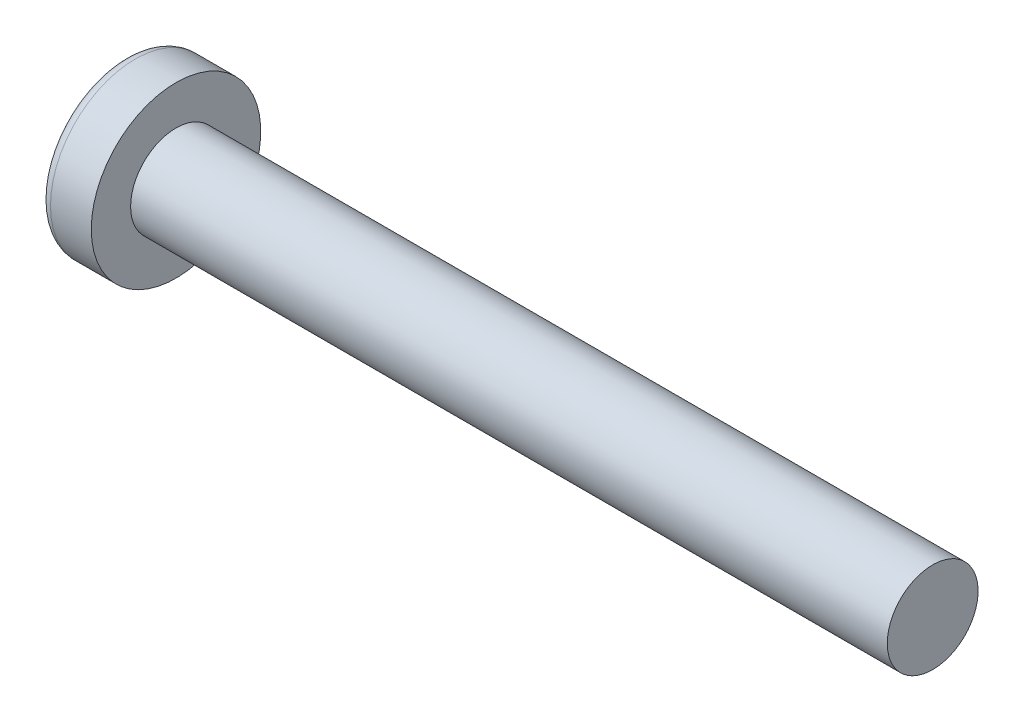
from build123d import *

# Parameters (mm, degrees)
SKETCH3_W         = 0.74
SKETCH3_H         = 2.9
SKETCH4_W         = 0.37
SKETCH4_H         = 0.37
CIRPATTERN1_COUNT = 2
CIRPATTERN1_ANGLE = 90


with BuildPart() as part:
    # BodySke → Base-Revolve (revolve)
    with BuildSketch(Plane.XY):
        with BuildLine():
            Line((2.4, 1.5), (2.4, 2.8))
            Line((2.4, 2.8), (1.053355856, 2.8))
            ThreePointArc((1.053355856, 2.8), (0.878072834, 2.754445324), (0.747150707, 2.629310345))
            ThreePointArc((0.747150707, 2.629310345), (0.190413403, 1.366702882), (0, 0))
            Line((0, 0), (27.4, 0))
            Line((27.4, 0), (27.4, 1.5))
            Line((27.4, 1.5), (2.4, 1.5))
        make_face()
    revolve(axis=Axis((-25.4, 0, 0), (1, 0, 0)))

    # Sketch3 → Cut-Loft1 section 0
    with BuildSketch(Plane(origin=(0, 0, 0), x_dir=(0, 0, -1), z_dir=(1, 0, 0))):
        Rectangle(SKETCH3_W, SKETCH3_H)
    # Sketch4 → Cut-Loft1 section 1
    with BuildSketch(Plane(origin=(1.76, 0, 0), x_dir=(0, 0, -1), z_dir=(1, 0, 0))):
        Rectangle(SKETCH4_W, SKETCH4_H)
    cut_loft1 = loft(mode=Mode.SUBTRACT)

    # CirPattern1: Cut-Loft1 ×2 about axis
    cirpattern1_axis = Axis((0, 0, 0), (1, 0, 0))
    for i in range(1, CIRPATTERN1_COUNT):
        add(cut_loft1.rotate(cirpattern1_axis, i * CIRPATTERN1_ANGLE / (CIRPATTERN1_COUNT - 1)), mode=Mode.SUBTRACT)


solid = part.part
